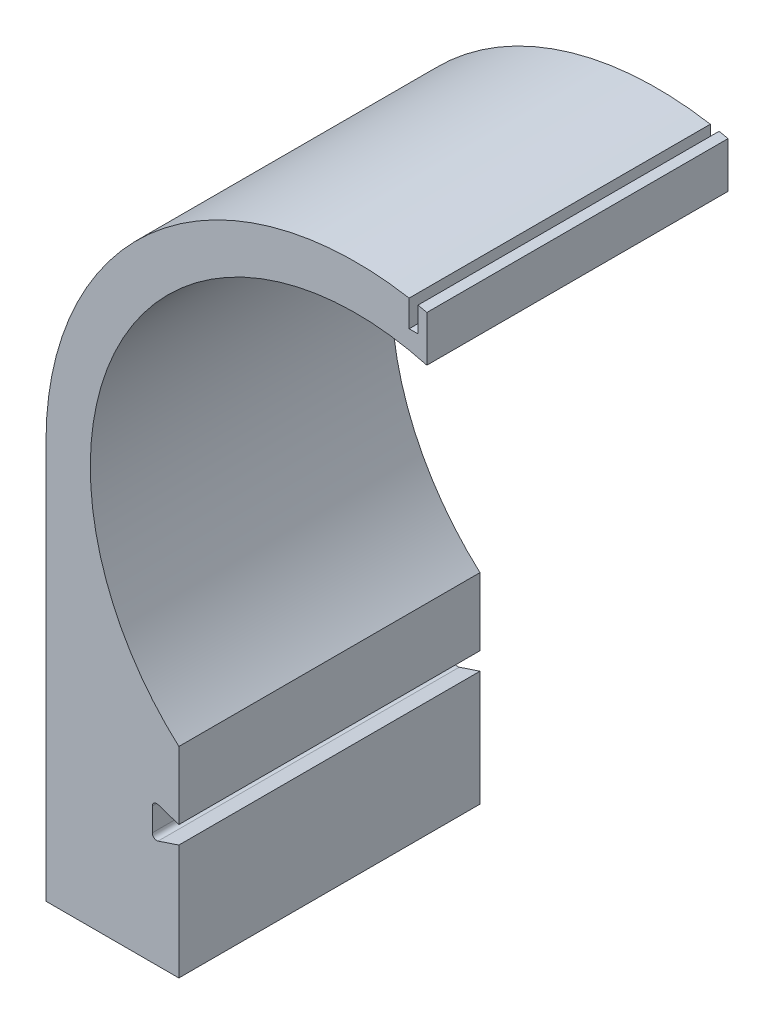
from build123d import *

# Parameters (mm, degrees)
INNER_RING_LEFT_SIDE_DEPTH = 170


with BuildPart() as part:
    # Sketch1 → Inner Ring - Left Side (new body)
    with BuildSketch(Plane.XY):
        with BuildLine():
            Line((-100, -111.803398875), (-100, -150))
            Line((-100, -150), (-111.709430585, -146.096856472))
            ThreePointArc((-111.709430585, -146.096856472), (-113.961775712, -146.440459254), (-115, -148.468564717))
            Line((-115, -148.468564717), (-115, -161.531435283))
            ThreePointArc((-115, -161.531435283), (-113.961775712, -163.559540746), (-111.709430585, -163.903143528))
            Line((-111.709430585, -163.903143528), (-100, -160))
            Line((-100, -160), (-100, -225))
            Line((-100, -225), (-175, -225))
            Line((-175, -225), (-175, 0))
            ThreePointArc((-175, 0), (-112.638803261, 133.93095236), (30, 172.409396496))
            Line((30, 172.409396496), (30, 157.409396496))
            Line((30, 157.409396496), (35, 157.409396496))
            Line((35, 157.409396496), (35, 171.464281995))
            ThreePointArc((35, 171.464281995), (37.50401138, 170.934049067), (40, 170.367250374))
            Line((40, 170.367250374), (40, 144.568322948))
            ThreePointArc((40, 144.568322948), (-131.649591483, 71.891481153), (-100, -111.803398875))
        make_face()
    extrude(amount=INNER_RING_LEFT_SIDE_DEPTH)


solid = part.part
